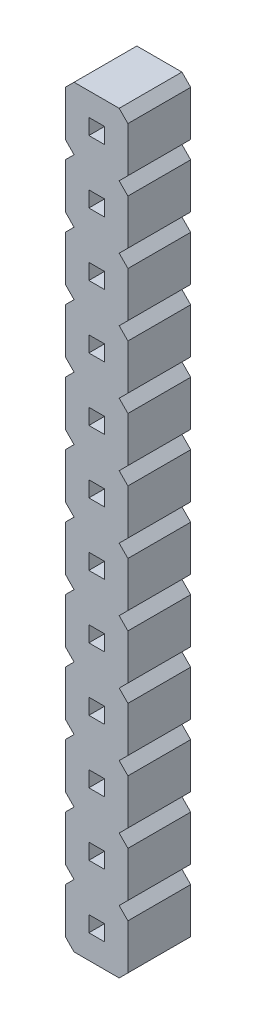
from build123d import *

# Parameters (mm, degrees)
PIN_DRAWING_W       = 0.636
PIN_DRAWING_H       = 0.636
BOSS_EXTRUDE1_DEPTH = 2.54


with BuildPart() as part:
    # pin_drawing → Boss-Extrude1 (new body)
    with BuildSketch(Plane.XY):
        Polygon((-0.014377737, 2.079116284), (-0.014377737, 0.25314904), (0.339175653, -0.107330326), (-0.014377737, -0.460883716), (-0.014377737, -2.28685096), (0.339175653, -2.647330326), (2.164719162, -2.647330326), (2.518272553, -2.293776935), (2.518272553, -0.46648), (2.164719162, -0.107330326), (2.518272553, 0.246223065), (2.518272553, 2.07352), (2.164719162, 2.432669674), (2.518272553, 2.786223065), (2.518272553, 4.61352), (2.164719162, 4.972669674), (2.518272553, 5.326223065), (2.518272553, 7.15352), (2.164719162, 7.512669674), (2.518272553, 7.866223065), (2.518272553, 9.69352), (2.164719162, 10.052669674), (2.518272553, 10.406223065), (2.518272553, 12.23352), (2.164719162, 12.592669674), (2.518272553, 12.946223065), (2.518272553, 14.77352), (2.164719162, 15.132669674), (2.518272553, 15.486223065), (2.518272553, 17.31352), (2.164719162, 17.672669674), (2.518272553, 18.026223065), (2.518272553, 19.85352), (2.164719162, 20.212669674), (2.518272553, 20.566223065), (2.518272553, 22.39352), (2.164719162, 22.752669674), (2.518272553, 23.106223065), (2.518272553, 24.93352), (2.164719162, 25.292669674), (2.518272553, 25.646223065), (2.518272553, 27.47352), (2.164719162, 27.832669674), (0.339175653, 27.832669674), (-0.014377737, 27.479116284), (-0.014377737, 25.65314904), (0.339175653, 25.292669674), (-0.014377737, 24.939116284), (-0.014377737, 23.11314904), (0.339175653, 22.752669674), (-0.014377737, 22.399116284), (-0.014377737, 20.57314904), (0.339175653, 20.212669674), (-0.014377737, 19.859116284), (-0.014377737, 18.03314904), (0.339175653, 17.672669674), (-0.014377737, 17.319116284), (-0.014377737, 15.49314904), (0.339175653, 15.132669674), (-0.014377737, 14.779116284), (-0.014377737, 12.95314904), (0.339175653, 12.592669674), (-0.014377737, 12.239116284), (-0.014377737, 10.41314904), (0.339175653, 10.052669674), (-0.014377737, 9.699116284), (-0.014377737, 7.87314904), (0.339175653, 7.512669674), (-0.014377737, 7.159116284), (-0.014377737, 5.33314904), (0.339175653, 4.972669674), (-0.014377737, 4.619116284), (-0.014377737, 2.79314904), (0.339175653, 2.432669674), align=None)
        with Locations((1.256122263, -1.357330326)):
            Rectangle(PIN_DRAWING_W, PIN_DRAWING_H, mode=Mode.SUBTRACT)
        with Locations((1.256122263, 1.182669674)):
            Rectangle(PIN_DRAWING_W, PIN_DRAWING_H, mode=Mode.SUBTRACT)
        with Locations((1.256122263, 3.722669674)):
            Rectangle(PIN_DRAWING_W, PIN_DRAWING_H, mode=Mode.SUBTRACT)
        with Locations((1.256122263, 6.262669674)):
            Rectangle(PIN_DRAWING_W, PIN_DRAWING_H, mode=Mode.SUBTRACT)
        with Locations((1.256122263, 8.802669674)):
            Rectangle(PIN_DRAWING_W, PIN_DRAWING_H, mode=Mode.SUBTRACT)
        with Locations((1.256122263, 11.342669674)):
            Rectangle(PIN_DRAWING_W, PIN_DRAWING_H, mode=Mode.SUBTRACT)
        with Locations((1.256122263, 13.882669674)):
            Rectangle(PIN_DRAWING_W, PIN_DRAWING_H, mode=Mode.SUBTRACT)
        with Locations((1.256122263, 16.422669674)):
            Rectangle(PIN_DRAWING_W, PIN_DRAWING_H, mode=Mode.SUBTRACT)
        with Locations((1.256122263, 18.962669674)):
            Rectangle(PIN_DRAWING_W, PIN_DRAWING_H, mode=Mode.SUBTRACT)
        with Locations((1.256122263, 21.502669674)):
            Rectangle(PIN_DRAWING_W, PIN_DRAWING_H, mode=Mode.SUBTRACT)
        with Locations((1.256122263, 24.042669674)):
            Rectangle(PIN_DRAWING_W, PIN_DRAWING_H, mode=Mode.SUBTRACT)
        with Locations((1.256122263, 26.582669674)):
            Rectangle(PIN_DRAWING_W, PIN_DRAWING_H, mode=Mode.SUBTRACT)
    extrude(amount=BOSS_EXTRUDE1_DEPTH)


solid = part.part
